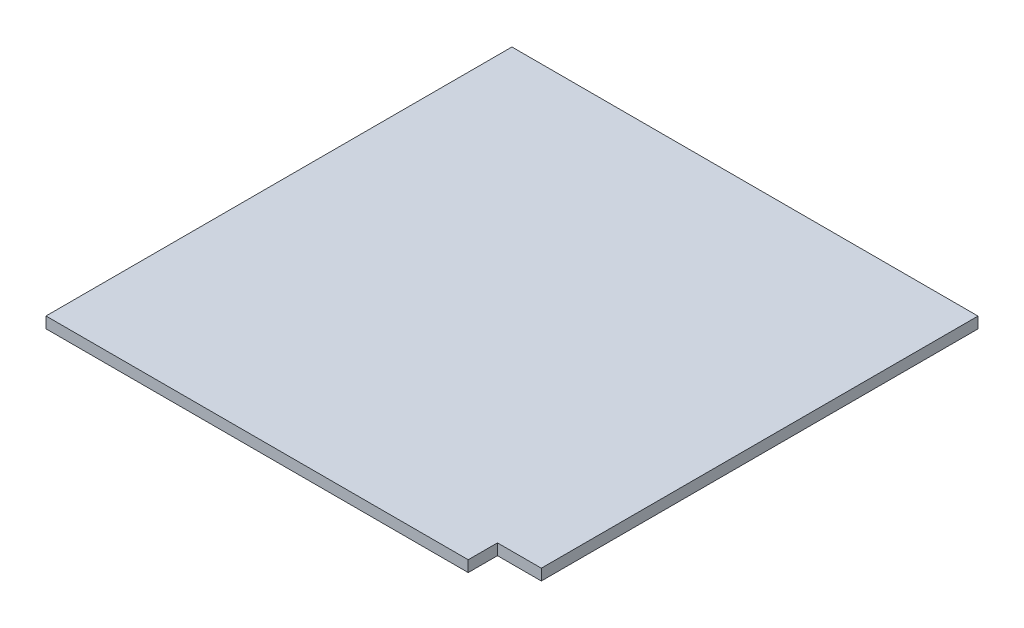
from build123d import *

# Parameters (mm, degrees)
BOSS_EXTRUDE1_DEPTH = 2.286


with BuildPart() as part:
    # Sketch1 → Boss-Extrude1 (new body)
    with BuildSketch(Plane(origin=(0, 0, 0), x_dir=(1, 0, 0), z_dir=(0, 1, 0))):
        Polygon((88.815, 0), (88.815, 6), (97.815, 6), (97.815, 95.6), (2.185, 95.6), (2.185, 0), align=None)
    extrude(amount=BOSS_EXTRUDE1_DEPTH)


solid = part.part
